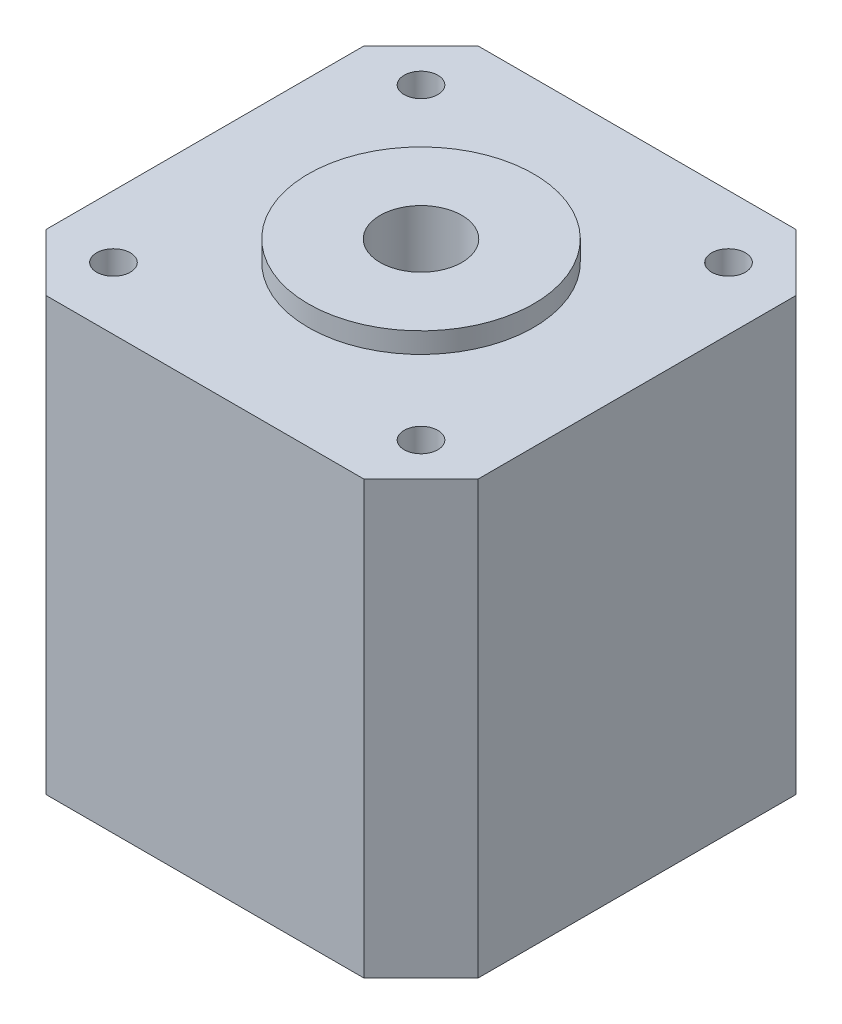
from build123d import *

# Parameters (mm, degrees)
ESBO_O1_W                = 42.3
ESBO_O1_H                = 42.3
RESSALTO_EXTRUS_O1_DEPTH = 21.15
ESBO_O2_R                = 11.025
RESSALTO_EXTRUS_O2_DEPTH = 2
CHANFRO1_SIZE            = 5.6
ESBO_O4_R                = 1.65
CORTE_EXTRUS_O1_DEPTH    = 10
ESBO_O3_R                = 4
CORTE_EXTRUS_O2_DEPTH    = 70


with BuildPart() as part:
    # Esboço1 → Ressalto-extrusão1 (new body, symmetric)
    with BuildSketch(Plane(origin=(0, 0, 0), x_dir=(1, 0, 0), z_dir=(0, 1, 0))):
        Rectangle(ESBO_O1_W, ESBO_O1_H)
    extrude(amount=RESSALTO_EXTRUS_O1_DEPTH, both=True)

    # Esboço2 → Ressalto-extrusão2 (add)
    with BuildSketch(Plane(origin=(0, 21.15, 0), x_dir=(1, 0, 0), z_dir=(0, 1, 0))):
        Circle(ESBO_O2_R)
    extrude(amount=RESSALTO_EXTRUS_O2_DEPTH)

    # Chanfro1
    chanfro1_edges = [part.edges().sort_by_distance(p)[0] for p in [
        (21.15, 0, 21.15),
        (-21.15, 0, 21.15),
        (-21.15, 0, -21.15),
        (21.15, 0, -21.15),
    ]]
    chamfer(chanfro1_edges, length=CHANFRO1_SIZE)

    # Esboço4 → Corte-extrusão1 (cut)
    with BuildSketch(Plane(origin=(0, 21.15, 0), x_dir=(1, 0, 0), z_dir=(0, 1, 0))):
        with Locations((-15.05, 15.05)):
            Circle(ESBO_O4_R)
        with Locations((15.05, 15.05)):
            Circle(ESBO_O4_R)
        with Locations((15.05, -15.05)):
            Circle(ESBO_O4_R)
        with Locations((-15.05, -15.05)):
            Circle(ESBO_O4_R)
    extrude(amount=-CORTE_EXTRUS_O1_DEPTH, mode=Mode.SUBTRACT)

    # Esboço3 → Corte-extrusão2 (cut)
    with BuildSketch(Plane(origin=(0, 23.15, 0), x_dir=(1, 0, 0), z_dir=(0, 1, 0))):
        Circle(ESBO_O3_R)
    extrude(amount=-CORTE_EXTRUS_O2_DEPTH, mode=Mode.SUBTRACT)


solid = part.part
